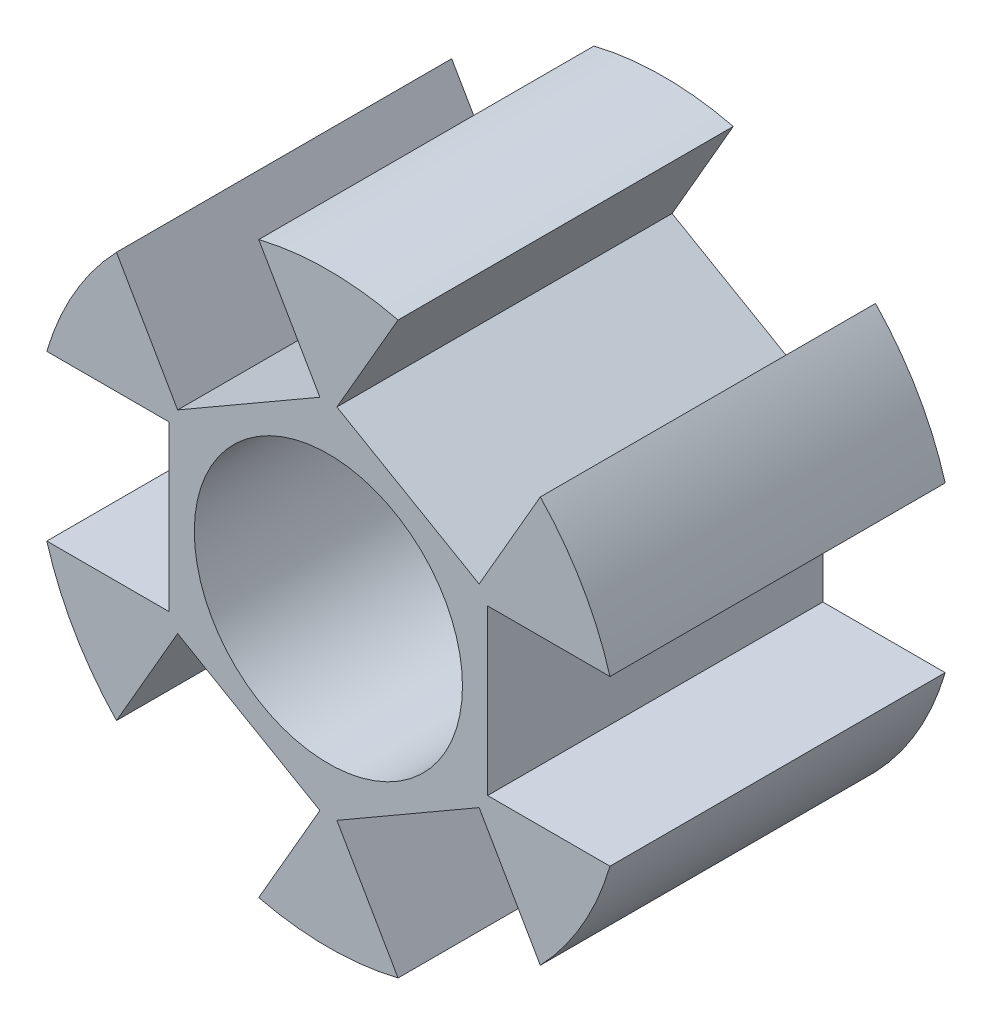
from build123d import *

# Parameters (mm, degrees)
SKETCH1_R           = 8.75
SKETCH1_R_2         = 4
BOSS_EXTRUDE1_DEPTH = 5
SKETCH2_W           = 4.9
SKETCH2_H           = 10
CUT_EXTRUDE3_DEPTH  = 4
CIRPATTERN1_COUNT   = 6


with BuildPart() as part:
    # Sketch1 → Boss-Extrude1 (new, symmetric)
    with BuildSketch(Plane.XY):
        Circle(SKETCH1_R)
        Circle(SKETCH1_R_2, mode=Mode.SUBTRACT)
    extrude(amount=BOSS_EXTRUDE1_DEPTH, both=True)

    # Sketch2 → Cut-Extrude3 (cut)
    with BuildSketch(Plane(origin=(-8.75, -17.193061184, 0), x_dir=(0, -1, 0), z_dir=(1, 0, 0))):
        with Locations((-17.193061184, 0)):
            Rectangle(SKETCH2_W, SKETCH2_H)
    cut_extrude3 = extrude(amount=CUT_EXTRUDE3_DEPTH, mode=Mode.SUBTRACT)

    # CirPattern1: Cut-Extrude3 ×6 about axis
    cirpattern1_axis = Axis((0, 0, 5), (0, 0, 1))
    for i in range(1, CIRPATTERN1_COUNT):
        add(cut_extrude3.rotate(cirpattern1_axis, i * 360 / CIRPATTERN1_COUNT), mode=Mode.SUBTRACT)


solid = part.part
